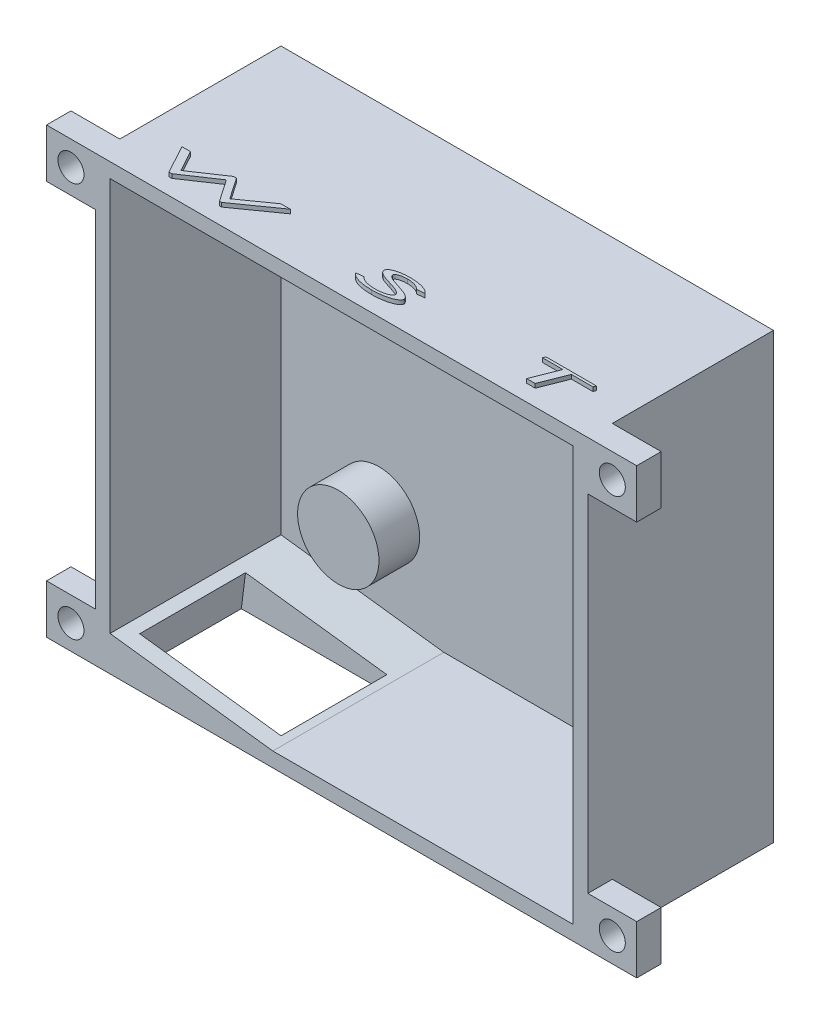
from build123d import *

# Parameters (mm, degrees)
CROQUIS1_W              = 60.5
CROQUIS1_H              = 54.5
SALIENTE_EXTRUIR1_DEPTH = 22.8
CROQUIS3_W              = 56.9
CROQUIS3_H              = 50.9
CORTAR_EXTRUIR1_DEPTH   = 21
CROQUIS5_R              = 5
CROQUIS5_W              = 10.5
CROQUIS5_H              = 8
CROQUIS5_R_2            = 2.1
CROQUIS5_W_2            = 8
CROQUIS5_H_2            = 7.5
SALIENTE_EXTRUIR2_DEPTH = 5
CROQUIS10_W             = 6
CROQUIS10_H             = 6
CROQUIS10_R             = 1.6
SALIENTE_EXTRUIR3_DEPTH = 3
SALIENTE_EXTRUIR4_DEPTH = 21
CORTAR_EXTRUIR5_REACH   = 7.234
CROQUIS12_W             = 17.5
CROQUIS12_H             = 13
SALIENTE_EXTRUIR5_DEPTH = 0.5


with BuildPart() as part:
    # Croquis1 → Saliente-Extruir1 (new body)
    with BuildSketch(Plane.XY):
        with Locations((-30.25, 27.25)):
            Rectangle(CROQUIS1_W, CROQUIS1_H)
    extrude(amount=SALIENTE_EXTRUIR1_DEPTH)

    # Croquis3 → Cortar-Extruir1 (cut)
    with BuildSketch(Plane.XY.offset(22.8)):
        with Locations((-30.25, 27.25)):
            Rectangle(CROQUIS3_W, CROQUIS3_H)
    extrude(amount=-CORTAR_EXTRUIR1_DEPTH, mode=Mode.SUBTRACT)

    # Croquis5 → Saliente-Extruir2 (add)
    with BuildSketch(Plane.XY.offset(1.8)):
        with Locations((-10.495867924, 44.921095302)):
            Circle(CROQUIS5_R)
        with Locations((-46.659301402, 12.57102915)):
            Circle(CROQUIS5_R)
        with Locations((-7.05, 5.8)):
            Rectangle(CROQUIS5_W, CROQUIS5_H)
        with Locations((-8.3, 5.8)):
            Circle(CROQUIS5_R_2, mode=Mode.SUBTRACT)
        with Locations((-47.7, 48.95)):
            Rectangle(CROQUIS5_W_2, CROQUIS5_H_2)
        with Locations((-47.7, 49.2)):
            Circle(CROQUIS5_R_2, mode=Mode.SUBTRACT)
    extrude(amount=SALIENTE_EXTRUIR2_DEPTH)

    # Croquis10 → Saliente-Extruir3 (add)
    with BuildSketch(Plane.XY.offset(22.8)):
        with Locations((-63.5, 51.5)):
            Rectangle(CROQUIS10_W, CROQUIS10_H)
        with Locations((-63.5, 51.5)):
            Circle(CROQUIS10_R, mode=Mode.SUBTRACT)
        with Locations((3, 51.5)):
            Rectangle(CROQUIS10_W, CROQUIS10_H)
        with Locations((3, 51.5)):
            Circle(CROQUIS10_R, mode=Mode.SUBTRACT)
        with Locations((3, 3)):
            Rectangle(CROQUIS10_W, CROQUIS10_H)
        with Locations((3, 3)):
            Circle(CROQUIS10_R, mode=Mode.SUBTRACT)
        with Locations((-63.5, 3)):
            Rectangle(CROQUIS10_W, CROQUIS10_H)
        with Locations((-63.5, 3)):
            Circle(CROQUIS10_R, mode=Mode.SUBTRACT)
    extrude(amount=-SALIENTE_EXTRUIR3_DEPTH)

    # Croquis11 → Saliente-Extruir4 (add)
    with BuildSketch(Plane.XY.offset(22.8)):
        Polygon((-58.7, 1.8), (-38.7, 1.8), (-58.7, 4.3), align=None)
    extrude(amount=-SALIENTE_EXTRUIR4_DEPTH)

    # Cortar-Extruir5: up to this face of the body (flat: up to its plane)
    cortar_extruir5_end = Plane(part.part.faces().sort_by_distance((-30.25, 0, 11.651801611))[0])
    # Croquis12 → Cortar-Extruir5 (cut, up to the picked face)
    with BuildSketch(Plane(origin=(-0.373846154, -2.990769231, 0), x_dir=(0.992277877, -0.124034735, 0), z_dir=(0.124034735, 0.992277877, 0)), mode=Mode.PRIVATE) as cortar_extruir5_sk1:
        with Locations((-48.374416351, -14.3)):
            Rectangle(CROQUIS12_W, CROQUIS12_H)
    cortar_extruir5_tool1 = split(extrude(cortar_extruir5_sk1.sketch, amount=-CORTAR_EXTRUIR5_REACH, mode=Mode.PRIVATE), bisect_by=cortar_extruir5_end, keep=Keep.BOTH, mode=Mode.PRIVATE)
    add(cortar_extruir5_tool1.solids().sort_by_distance((-48.374709, 3.009339, 14.3))[0], mode=Mode.SUBTRACT)

    # Croquis9 → Saliente-Extruir5 (add)
    with BuildSketch(Plane(origin=(0, 54.5, 0), x_dir=(1, 0, 0), z_dir=(0, 1, 0))):
        Polygon((-55.374204265, -17.288095437), (-54.323222695, -17.288095437), (-52.906255547, -19.89065954), (-49.033258752, -17.288095437), (-48.681295611, -17.288095437), (-46.893435034, -19.89065954), (-43.213947855, -17.288095437), (-42.071820451, -17.288095437), (-47.019636957, -20.788095437), (-47.265029586, -20.788095437), (-49.114588881, -18.095787745), (-53.120798816, -20.788095437), (-53.468555227, -20.788095437), align=None)
        with BuildLine():
            Line((-24.830501634, -17.968183578), (-25.807865416, -18.05091595))
            add(Edge.make_bspline(
                [(-25.807865416, -18.05091595), (-25.825465392, -18.030441479), (-25.861516507, -17.988502359), (-25.924445858, -17.931429676), (-25.995089145, -17.877145838), (-26.073678474, -17.826151019), (-26.160348774, -17.778329764), (-26.255120706, -17.734412769), (-26.35799054, -17.693773865), (-26.467844467, -17.656522125), (-26.582598554, -17.622287696), (-26.70051084, -17.592841933), (-26.8208011, -17.568363049), (-26.943137369, -17.548230245), (-27.067722757, -17.531721004), (-27.194771081, -17.520934042), (-27.324068083, -17.51345402), (-27.41108638, -17.512788659), (-27.454800512, -17.512454412)],
                knots=[0, 0, 0, 0, 8.0933e-05, 0.000165781, 0.000254269, 0.000348002, 0.000446542, 0.000550992, 0.000661138, 0.000778206, 0.000898885, 0.001020298, 0.001142676, 0.001267045, 0.001392187, 0.001519585, 0.001649482, 0.001780608, 0.001780608, 0.001780608, 0.001780608], degree=3))
            add(Edge.make_bspline(
                [(-27.454800512, -17.512454412), (-27.502484154, -17.512840143), (-27.595791335, -17.513594942), (-27.732354406, -17.52000794), (-27.86216621, -17.530317744), (-27.985180598, -17.545104141), (-28.101600738, -17.563519977), (-28.210938461, -17.587720107), (-28.313613833, -17.614673337), (-28.408468487, -17.645977051), (-28.494433285, -17.68045302), (-28.56977202, -17.718303529), (-28.634534525, -17.758148386), (-28.686038886, -17.803252683), (-28.728347054, -17.849363411), (-28.757139024, -17.900029673), (-28.776353361, -17.953272589), (-28.778258953, -17.990222021), (-28.779219583, -18.008848642)],
                knots=[0, 0, 0, 0, 0.000143044, 0.000279909, 0.000410042, 0.000533618, 0.000651534, 0.000763477, 0.00086943, 0.000969866, 0.001062957, 0.00114699, 0.001222649, 0.001290255, 0.001351859, 0.001409342, 0.001464106, 0.001519778, 0.001519778, 0.001519778, 0.001519778], degree=3))
            add(Edge.make_bspline(
                [(-28.779219583, -18.008848642), (-28.777861411, -18.025590285), (-28.77503265, -18.060459296), (-28.755386206, -18.112117751), (-28.724627913, -18.164049091), (-28.680416903, -18.215402483), (-28.625032194, -18.267535344), (-28.557548219, -18.320318857), (-28.478034889, -18.373602879), (-28.419542187, -18.407000748), (-28.388694743, -18.424613867)],
                knots=[0, 0, 0, 0, 5.0178e-05, 0.000104509, 0.00016391, 0.000230609, 0.000306983, 0.000391845, 0.000487324, 0.000593862, 0.000593862, 0.000593862, 0.000593862], degree=3))
            add(Edge.make_bspline(
                [(-28.388694743, -18.424613867), (-28.377737098, -18.430506911), (-28.354352458, -18.443083219), (-28.316107152, -18.462228714), (-28.27251164, -18.482095205), (-28.223462792, -18.503455707), (-28.169424052, -18.52556224), (-28.109661863, -18.548742949), (-28.045286887, -18.57425834), (-27.974477687, -18.598953956), (-27.899288158, -18.626659109), (-27.81828283, -18.654547739), (-27.732235308, -18.683864497), (-27.641033386, -18.715018383), (-27.544125335, -18.746347531), (-27.441955818, -18.779174826), (-27.334622249, -18.813843176), (-27.261084727, -18.836493487), (-27.22343032, -18.848091431)],
                knots=[0, 0, 0, 0, 3.7324e-05, 7.9654e-05, 0.00012828, 0.000181032, 0.000240143, 0.000303419, 0.000373338, 0.000447855, 0.000528362, 0.000613729, 0.000704856, 0.000801081, 0.00090285, 0.001010387, 0.001123026, 0.001241224, 0.001241224, 0.001241224, 0.001241224], degree=3))
            add(Edge.make_bspline(
                [(-27.22343032, -18.848091431), (-27.146492783, -18.872004023), (-26.998134794, -18.918114467), (-26.784823454, -18.987215621), (-26.590639502, -19.058177217), (-26.413558675, -19.125223967), (-26.255343202, -19.192866577), (-26.114104051, -19.25742994), (-25.991835472, -19.322332566), (-25.8864413, -19.385966481), (-25.796382432, -19.448912305), (-25.71899524, -19.511170345), (-25.653132408, -19.573106092), (-25.598447283, -19.634432835), (-25.55644205, -19.696528267), (-25.526703358, -19.758158282), (-25.506592743, -19.819298062), (-25.504569997, -19.860599915), (-25.503578557, -19.880843835)],
                knots=[0, 0, 0, 0, 0.000241709, 0.000466086, 0.000672565, 0.000861884, 0.001034041, 0.001188684, 0.00132763, 0.001449076, 0.001557806, 0.001657012, 0.00174678, 0.001828763, 0.001903046, 0.001970779, 0.002033771, 0.002094328, 0.002094328, 0.002094328, 0.002094328], degree=3))
            add(Edge.make_bspline(
                [(-25.503578557, -19.880843835), (-25.504788591, -19.902023307), (-25.507259577, -19.945273485), (-25.528242963, -20.00897019), (-25.561450286, -20.071558383), (-25.606980369, -20.133673026), (-25.665992517, -20.194755319), (-25.738288661, -20.254675665), (-25.822387387, -20.315066556), (-25.919385684, -20.373282158), (-26.026447704, -20.43041021), (-26.143441169, -20.484225746), (-26.268929846, -20.535612191), (-26.404053251, -20.58265539), (-26.547483293, -20.628836499), (-26.700549211, -20.669447904), (-26.862062983, -20.708146641), (-27.090515687, -20.756142152), (-27.387500248, -20.804388352), (-27.753545031, -20.847556918), (-28.130315777, -20.873072001), (-28.385150759, -20.876236546), (-28.514195544, -20.877839027)],
                knots=[0, 0, 0, 0, 6.3416e-05, 0.0001295, 0.00019912, 0.00027541, 0.000359714, 0.000453255, 0.000556765, 0.000670035, 0.00079236, 0.000920657, 0.001056194, 0.001199002, 0.001349784, 0.001508128, 0.001673932, 0.001848017, 0.002208331, 0.002576111, 0.002953458, 0.003340569, 0.003340569, 0.003340569, 0.003340569], degree=3))
            add(Edge.make_bspline(
                [(-28.514195544, -20.877839027), (-28.596004613, -20.877154575), (-28.756644026, -20.875810592), (-28.993467652, -20.865565728), (-29.222025434, -20.850276964), (-29.442156126, -20.825722217), (-29.654406025, -20.796928095), (-29.858072081, -20.760371402), (-30.053713365, -20.717780513), (-30.24019018, -20.668249369), (-30.416392561, -20.612794971), (-30.580230866, -20.550666035), (-30.730765581, -20.481473591), (-30.869557755, -20.407912237), (-30.994617497, -20.326380871), (-31.106584003, -20.23903399), (-31.207194216, -20.14673857), (-31.26402067, -20.078065735), (-31.292040096, -20.044205213)],
                knots=[0, 0, 0, 0, 0.000245418, 0.0004819, 0.000711033, 0.000932472, 0.001146249, 0.001353507, 0.001553056, 0.001746761, 0.001932134, 0.002107007, 0.002272031, 0.002428877, 0.002577839, 0.00271921, 0.002854628, 0.002986344, 0.002986344, 0.002986344, 0.002986344], degree=3))
            Line((-31.292040096, -20.044205213), (-30.335008846, -19.935531335))
            add(Edge.make_bspline(
                [(-30.335008846, -19.935531335), (-30.314978195, -19.96169555), (-30.274435143, -20.014653248), (-30.202909541, -20.086516648), (-30.123056715, -20.153842065), (-30.033698855, -20.215153823), (-29.9359034, -20.271935071), (-29.829525344, -20.324264721), (-29.713660584, -20.369942725), (-29.589753672, -20.41102625), (-29.458992289, -20.447500198), (-29.322355923, -20.477671257), (-29.18121746, -20.504682336), (-29.035242839, -20.526218503), (-28.88417695, -20.543150715), (-28.728167518, -20.554545308), (-28.567338942, -20.562975537), (-28.458584816, -20.563480378), (-28.403418301, -20.563736463)],
                knots=[0, 0, 0, 0, 9.8766e-05, 0.000199908, 0.000303413, 0.000411742, 0.000524538, 0.000642437, 0.000767034, 0.000897845, 0.00103393, 0.001174086, 0.001317507, 0.001464951, 0.001616629, 0.001773433, 0.001934175, 0.002099653, 0.002099653, 0.002099653, 0.002099653], degree=3))
            add(Edge.make_bspline(
                [(-28.403418301, -20.563736463), (-28.340771911, -20.563284782), (-28.217513462, -20.562396087), (-28.036069671, -20.552816511), (-27.861084005, -20.53853915), (-27.693183227, -20.517407953), (-27.53170674, -20.490943888), (-27.377119972, -20.457952358), (-27.228848261, -20.41971509), (-27.089405837, -20.375286591), (-26.961636572, -20.327099985), (-26.848705228, -20.276022499), (-26.753654442, -20.220360065), (-26.674471648, -20.163740056), (-26.61346196, -20.102423463), (-26.568589034, -20.038951398), (-26.540412564, -19.971159621), (-26.537211861, -19.924325314), (-26.535629839, -19.901176367)],
                knots=[0, 0, 0, 0, 0.000187922, 0.000369741, 0.00054494, 0.000714519, 0.000877271, 0.001035684, 0.001188564, 0.001336461, 0.001474488, 0.001598084, 0.001707751, 0.001804508, 0.001889286, 0.00196591, 0.002036738, 0.002105961, 0.002105961, 0.002105961, 0.002105961], degree=3))
            add(Edge.make_bspline(
                [(-26.535629839, -19.901176367), (-26.536592141, -19.884008563), (-26.538551199, -19.849058284), (-26.554397988, -19.797511093), (-26.578505494, -19.745984421), (-26.61359761, -19.695800052), (-26.657679995, -19.645386873), (-26.711928793, -19.59610561), (-26.775615217, -19.546903412), (-26.849949385, -19.497021229), (-26.938464747, -19.445744093), (-27.044628185, -19.393802221), (-27.1692467, -19.339309497), (-27.312296917, -19.281902621), (-27.474218712, -19.222663646), (-27.654825569, -19.161174282), (-27.853840477, -19.096478447), (-27.993410982, -19.054416341), (-28.066178717, -19.032486463)],
                knots=[0, 0, 0, 0, 5.1417e-05, 0.000104674, 0.0001605, 0.000221562, 0.00028765, 0.000361084, 0.000441025, 0.00052892, 0.000629452, 0.000747661, 0.000883275, 0.001037426, 0.001210002, 0.001400461, 0.001609766, 0.001837761, 0.001837761, 0.001837761, 0.001837761], degree=3))
            add(Edge.make_bspline(
                [(-28.066178717, -19.032486463), (-28.1059118, -19.020343042), (-28.18353752, -18.996618687), (-28.297235057, -18.961698281), (-28.405449105, -18.92734738), (-28.508007281, -18.893324185), (-28.606140734, -18.862409819), (-28.698000956, -18.830205144), (-28.785648773, -18.801427528), (-28.867015081, -18.77144693), (-28.943944277, -18.744396334), (-29.015279143, -18.717865013), (-29.081088149, -18.691884466), (-29.141532957, -18.667138134), (-29.196995884, -18.644458146), (-29.246724994, -18.621599325), (-29.291753145, -18.601102822), (-29.319378738, -18.586464162), (-29.332404679, -18.579561783)],
                knots=[0, 0, 0, 0, 0.000124642, 0.000243511, 0.000356817, 0.000465237, 0.000567673, 0.000665451, 0.000757242, 0.000844399, 0.000925565, 0.001001882, 0.001072709, 0.001137807, 0.001197834, 0.001252436, 0.001301993, 0.001346208, 0.001346208, 0.001346208, 0.001346208], degree=3))
            add(Edge.make_bspline(
                [(-29.332404679, -18.579561783), (-29.370158999, -18.558178021), (-29.442282125, -18.517328025), (-29.539554353, -18.449903642), (-29.622923405, -18.382710582), (-29.69069467, -18.313820351), (-29.744794871, -18.244259208), (-29.782203982, -18.172720579), (-29.80662991, -18.100389931), (-29.809735552, -18.051330811), (-29.811270865, -18.027077809)],
                knots=[0, 0, 0, 0, 0.000130107, 0.000248547, 0.000354657, 0.000450841, 0.000537922, 0.000617892, 0.000692175, 0.000764801, 0.000764801, 0.000764801, 0.000764801], degree=3))
            add(Edge.make_bspline(
                [(-29.811270865, -18.027077809), (-29.810750641, -18.012308935), (-29.809709997, -17.982765629), (-29.800647505, -17.93909402), (-29.787650377, -17.896080422), (-29.768229029, -17.854306605), (-29.74350121, -17.813436135), (-29.713210841, -17.773709035), (-29.677980423, -17.734528822), (-29.636132962, -17.697886489), (-29.589763751, -17.661080085), (-29.537721025, -17.625705266), (-29.480788101, -17.590157363), (-29.417768328, -17.55695407), (-29.34920122, -17.52482186), (-29.275843124, -17.492312261), (-29.196667016, -17.461734483), (-29.082677606, -17.42213251), (-28.931869724, -17.375238498), (-28.7412297, -17.328059024), (-28.539973393, -17.288158294), (-28.328478311, -17.255562677), (-28.106572463, -17.22942721), (-27.87406664, -17.211751087), (-27.631136416, -17.200062925), (-27.465565309, -17.198929495), (-27.381182724, -17.198351847)],
                knots=[0, 0, 0, 0, 4.426e-05, 8.8536e-05, 0.000133331, 0.000178823, 0.000226318, 0.000276379, 0.000328493, 0.000384099, 0.00044301, 0.000506021, 0.00057276, 0.000644275, 0.000719543, 0.000799916, 0.000884937, 0.000974076, 0.001161915, 0.00135849, 0.001562954, 0.001777242, 0.00200031, 0.002233096, 0.002476644, 0.002729773, 0.002729773, 0.002729773, 0.002729773], degree=3))
            add(Edge.make_bspline(
                [(-27.381182724, -17.198351847), (-27.30965887, -17.19883045), (-27.168420775, -17.199775545), (-26.959373099, -17.20908112), (-26.756212174, -17.224563475), (-26.559030167, -17.245297361), (-26.367951348, -17.272632053), (-26.183018613, -17.306353721), (-26.003765884, -17.345432137), (-25.831578018, -17.390715143), (-25.667506511, -17.441342737), (-25.514160309, -17.498674337), (-25.371756798, -17.561615702), (-25.241107542, -17.631132653), (-25.121360665, -17.706062708), (-25.013073459, -17.786961131), (-24.914969856, -17.872908988), (-24.85839313, -17.936723808), (-24.830501634, -17.968183578)],
                knots=[0, 0, 0, 0, 0.000214562, 0.000423695, 0.000627604, 0.000825739, 0.001018394, 0.001206525, 0.001389572, 0.001568645, 0.001740506, 0.001904462, 0.002059509, 0.00220724, 0.002348075, 0.002482831, 0.00261244, 0.002738462, 0.002738462, 0.002738462, 0.002738462], degree=3))
        make_face()
        Polygon((-10.645116292, -17.288095437), (-4.451406356, -17.288095437), (-4.585320619, -17.602198001), (-7.229250908, -17.602198001), (-8.480753312, -20.788095437), (-9.521919177, -20.788095437), (-8.269715651, -17.602198001), (-10.778329433, -17.602198001), align=None)
    extrude(amount=SALIENTE_EXTRUIR5_DEPTH)


solid = part.part
